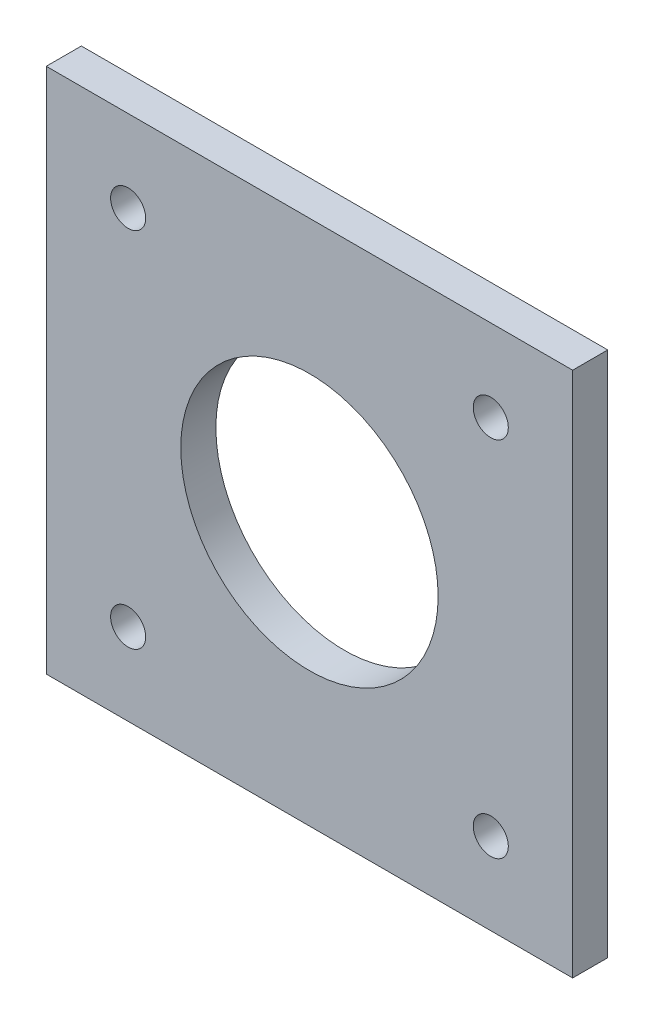
from build123d import *

# Parameters (mm, degrees)
SKETCH1_W           = 45
SKETCH1_H           = 45
SKETCH1_R           = 11
SKETCH1_R_2         = 1.5
BOSS_EXTRUDE1_DEPTH = 3


with BuildPart() as part:
    # Sketch1 → Boss-Extrude1 (new body)
    with BuildSketch(Plane.XY):
        Rectangle(SKETCH1_W, SKETCH1_H)
        Polygon((20.15, -20.15), (20.15, -16.735786438), (20.15, 16.735786438), (16.735786438, 20.15), (-16.735786438, 20.15), (-20.15, 16.735786438), (-20.15, 16.077064234), (-20.15, -16.735786438), (-20.15, -20.15), (-16.735786438, -20.15), (16.735786438, -20.15), align=None, mode=Mode.SUBTRACT)
        Polygon((16.735786438, -20.15), (20.15, -20.15), (20.15, -16.735786438), (20.15, 16.735786438), (16.735786438, 20.15), (-16.735786438, 20.15), (-20.15, 16.735786438), (-20.15, 16.077064234), (-20.15, -16.735786438), (-20.15, -20.15), (-16.735786438, -20.15), align=None)
        Circle(SKETCH1_R, mode=Mode.SUBTRACT)
        with Locations((15.5, -15.5)):
            Circle(SKETCH1_R_2, mode=Mode.SUBTRACT)
        with Locations((15.5, 15.5)):
            Circle(SKETCH1_R_2, mode=Mode.SUBTRACT)
        with Locations((-15.5, -15.5)):
            Circle(SKETCH1_R_2, mode=Mode.SUBTRACT)
        with Locations((-15.5, 15.5)):
            Circle(SKETCH1_R_2, mode=Mode.SUBTRACT)
    extrude(amount=BOSS_EXTRUDE1_DEPTH)


solid = part.part
